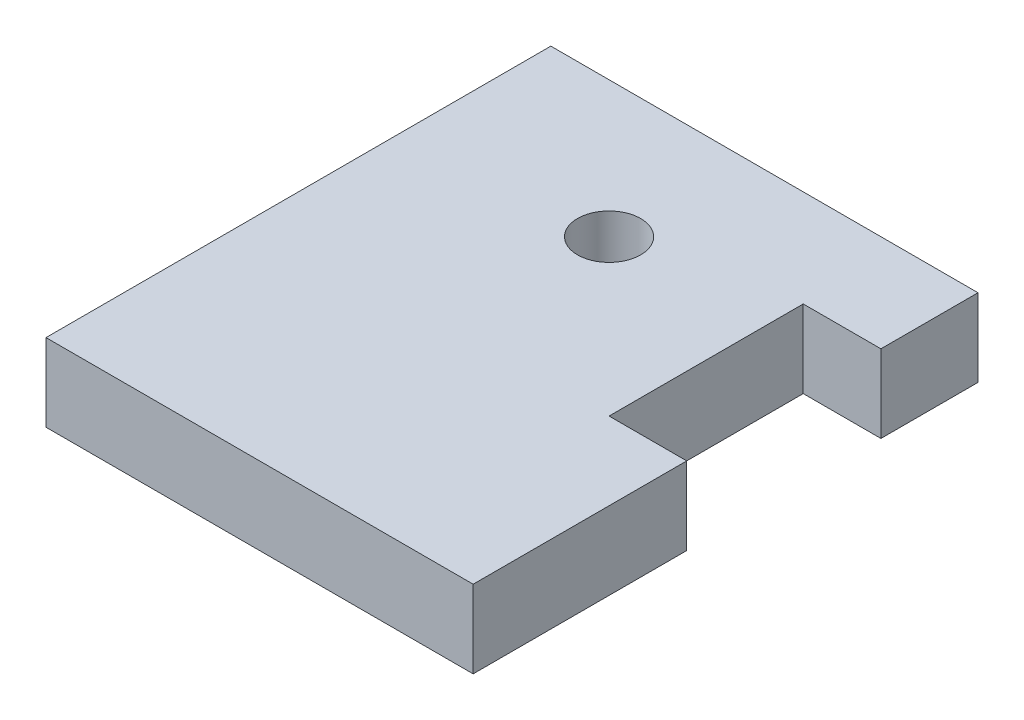
from build123d import *

# Parameters (mm, degrees)
SKETCH1_R           = 1.625
BOSS_EXTRUDE1_DEPTH = 4


with BuildPart() as part:
    # Sketch1 → Boss-Extrude1 (new body)
    with BuildSketch(Plane(origin=(0, 0, 0), x_dir=(1, 0, 0), z_dir=(0, 1, 0))):
        Polygon((0, 0), (22, 0), (22, 11), (18, 11), (18, 21), (22, 21), (22, 26), (0, 26), align=None)
        with Locations((10, 19)):
            Circle(SKETCH1_R, mode=Mode.SUBTRACT)
    extrude(amount=BOSS_EXTRUDE1_DEPTH)


solid = part.part
